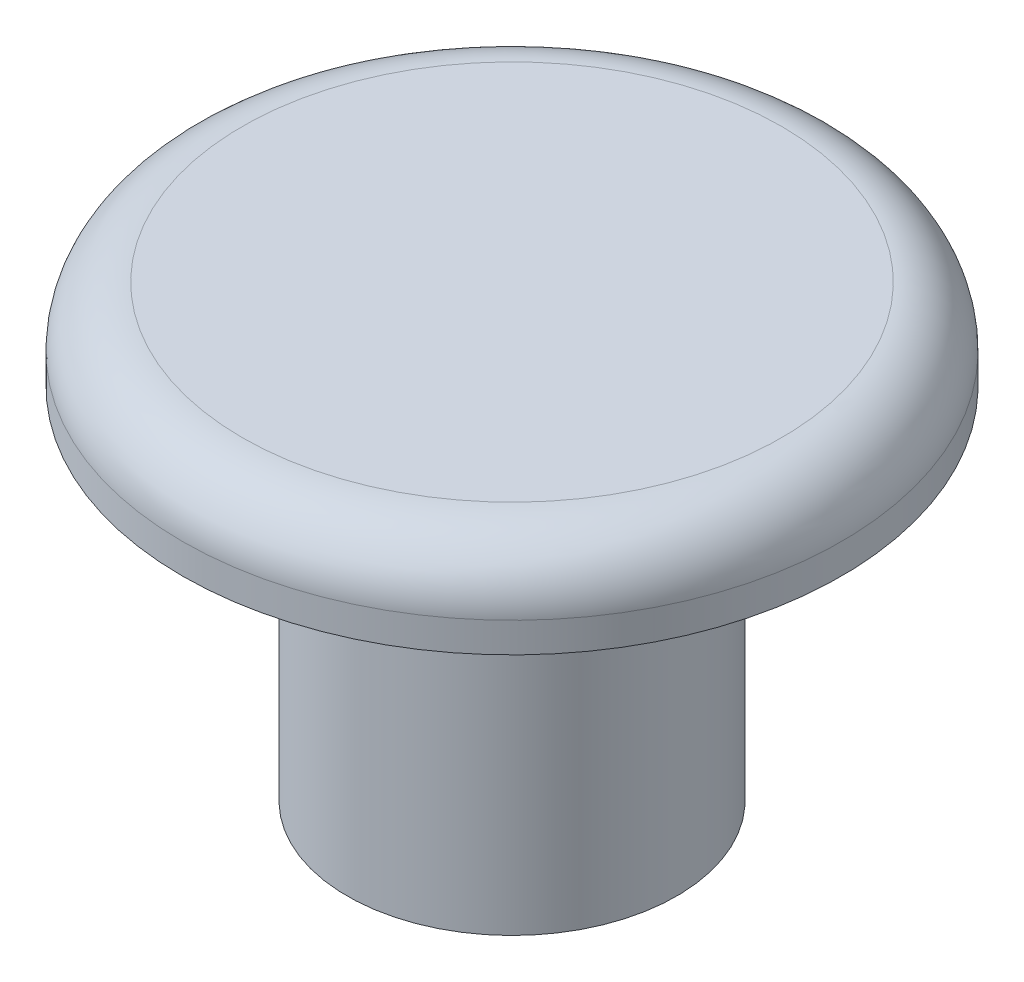
from build123d import *

# Parameters (mm, degrees)
SKETCH1_R           = 11
BOSS_EXTRUDE1_DEPTH = 3
SKETCH2_R           = 5.5
BOSS_EXTRUDE2_DEPTH = 12
FILLET1_R           = 2


with BuildPart() as part:
    # Sketch1 → Boss-Extrude1 (new body)
    with BuildSketch(Plane(origin=(0, 0, 0), x_dir=(1, 0, 0), z_dir=(0, 1, 0))):
        Circle(SKETCH1_R)
    extrude(amount=BOSS_EXTRUDE1_DEPTH)

    # Sketch2 → Boss-Extrude2 (add)
    with BuildSketch(Plane.XZ):
        Circle(SKETCH2_R)
    extrude(amount=BOSS_EXTRUDE2_DEPTH)

    # Fillet1
    fillet1_edges = [part.edges().sort_by_distance(p)[0] for p in [
        (-11, 3, 0),
    ]]
    fillet(fillet1_edges, radius=FILLET1_R)


solid = part.part
